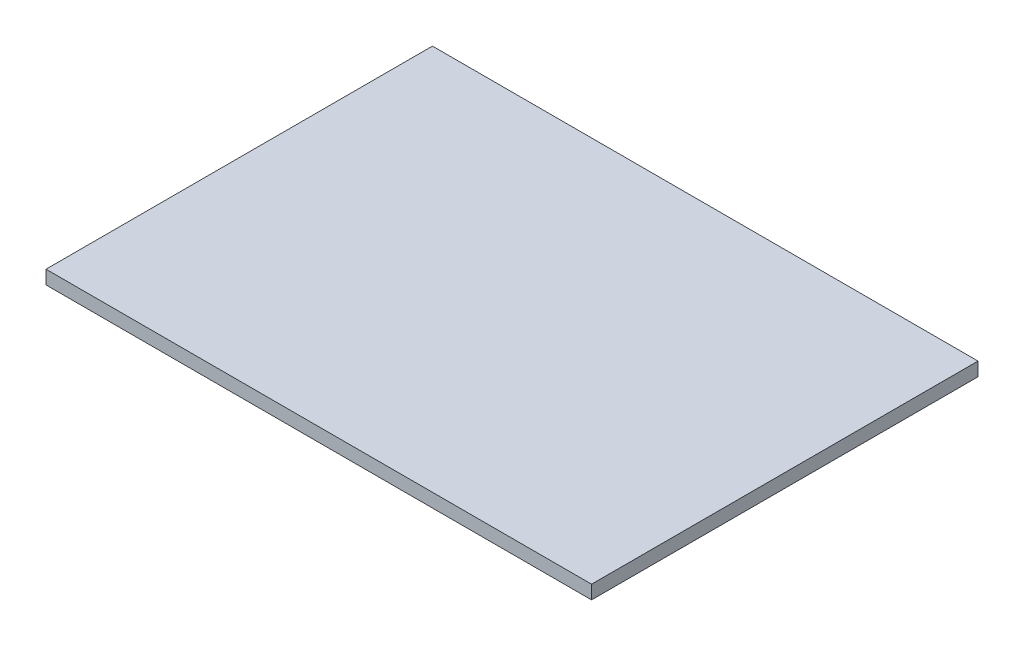
from build123d import *

# Parameters (mm, degrees)
SKETCH_1_W      = 120
SKETCH_1_H      = 85
EXTRUDE_1_DEPTH = 3


with BuildPart() as part:
    # Эскиз1 → Бобышка-Вытянуть1 (new body)
    with BuildSketch(Plane(origin=(0, 0, 0), x_dir=(1, 0, 0), z_dir=(0, 1, 0))):
        Rectangle(SKETCH_1_W, SKETCH_1_H)
    extrude(amount=EXTRUDE_1_DEPTH)


solid = part.part
